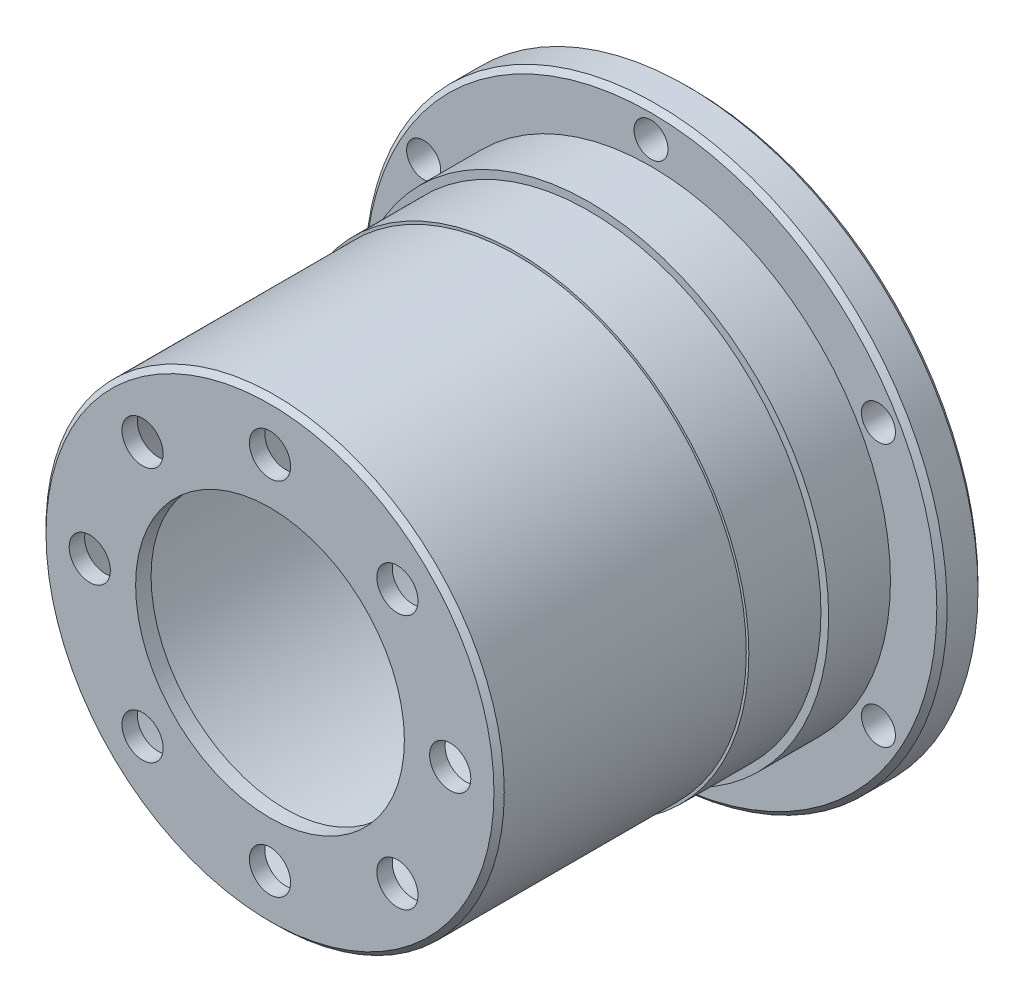
from build123d import *

# Parameters (mm, degrees)
SKETCH_1_R               = 22.25
SKETCH_1_R_2             = 21.05
EXTRUDE_1_DEPTH          = 41
SKETCH_2_R               = 22.25
SKETCH_2_R_2             = 13.05
EXTRUDE_2_DEPTH          = 1.5
SKETCH_3_R               = 28.25
SKETCH_3_R_2             = 21.05
EXTRUDE_3_DEPTH          = 4
SKETCH_4_R               = 23.25
SKETCH_4_R_2             = 22.25
EXTRUDE_4_DEPTH          = 6
SKETCH_5_R               = 22.5
SKETCH_5_R_2             = 22.25
EXTRUDE_5_DEPTH          = 7
SKETCH_6_R               = 2
CUT_EXTRUDE_1_DEPTH      = 7
PATTERN_CIRCULAR_1_COUNT = 6
CHAMFER_1_SIZE           = 0.5


with BuildPart() as part:
    # 草图1 → 凸台-拉伸1 (new body)
    with BuildSketch(Plane.XY):
        Circle(SKETCH_1_R)
        Circle(SKETCH_1_R_2, mode=Mode.SUBTRACT)
    extrude(amount=EXTRUDE_1_DEPTH)

    # 草图2 → 凸台-拉伸2 (add)
    with BuildSketch(Plane.XY.offset(41)):
        Circle(SKETCH_2_R)
        Circle(SKETCH_2_R_2, mode=Mode.SUBTRACT)
    extrude(amount=-EXTRUDE_2_DEPTH)

    # 草图3 → 凸台-拉伸3 (add)
    with BuildSketch(Plane(origin=(0, 0, 0), x_dir=(-1, 0, 0), z_dir=(0, 0, -1))):
        Circle(SKETCH_3_R)
        Circle(SKETCH_3_R_2, mode=Mode.SUBTRACT)
    extrude(amount=-EXTRUDE_3_DEPTH)

    # 草图4 → 凸台-拉伸4 (add)
    with BuildSketch(Plane.XY.offset(4)):
        Circle(SKETCH_4_R)
        Circle(SKETCH_4_R_2, mode=Mode.SUBTRACT)
    extrude(amount=EXTRUDE_4_DEPTH)

    # 草图5 → 凸台-拉伸5 (add)
    with BuildSketch(Plane.XY.offset(10)):
        Circle(SKETCH_5_R)
        Circle(SKETCH_5_R_2, mode=Mode.SUBTRACT)
    extrude(amount=EXTRUDE_5_DEPTH)

    # 草图6 → 切除-拉伸1 (cut)
    with BuildSketch(Plane(origin=(0, 0, 39.5), x_dir=(-1, 0, 0), z_dir=(0, 0, -1))):
        with Locations((12.374368671, 12.374368671)):
            Circle(SKETCH_6_R)
        with Locations((17.5, 0)):
            Circle(SKETCH_6_R)
        with Locations((12.374368671, -12.374368671)):
            Circle(SKETCH_6_R)
        with Locations((0, -17.5)):
            Circle(SKETCH_6_R)
        with Locations((-12.374368671, -12.374368671)):
            Circle(SKETCH_6_R)
        with Locations((-17.5, 0)):
            Circle(SKETCH_6_R)
        with Locations((-12.374368671, 12.374368671)):
            Circle(SKETCH_6_R)
        with Locations((0, 17.5)):
            Circle(SKETCH_6_R)
    extrude(amount=-CUT_EXTRUDE_1_DEPTH, mode=Mode.SUBTRACT)

    # 草图9 → M4 螺纹孔1 (revolve, cut)
    with BuildSketch(Plane(origin=(0, 25.5, 4), x_dir=(0, -1, 0), z_dir=(1, 0, 0))):
        Polygon((0, 0), (0, 11.091420021), (1.65, 10.1), (1.65, 0), align=None)
    hole_wizard_m4_1 = revolve(axis=Axis((0, 25.5, 10.35), (0, 0, -1)), mode=Mode.SUBTRACT)

    # 阵列(圆周)1: M4 螺纹孔1 ×6 about axis
    pattern_circular_1_axis = Axis((0, 0, 0), (0, 0, 1))
    for i in range(1, PATTERN_CIRCULAR_1_COUNT):
        add(hole_wizard_m4_1.rotate(pattern_circular_1_axis, i * 360 / PATTERN_CIRCULAR_1_COUNT), mode=Mode.SUBTRACT)

    # 倒角1
    chamfer_1_edges = [part.edges().sort_by_distance(p)[0] for p in [
        (28.25, 0, 4),
        (28.25, 0, 0),
        (-22.25, 0, 41),
        (-21.05, 0, 0),
    ]]
    chamfer(chamfer_1_edges, length=CHAMFER_1_SIZE)


solid = part.part
